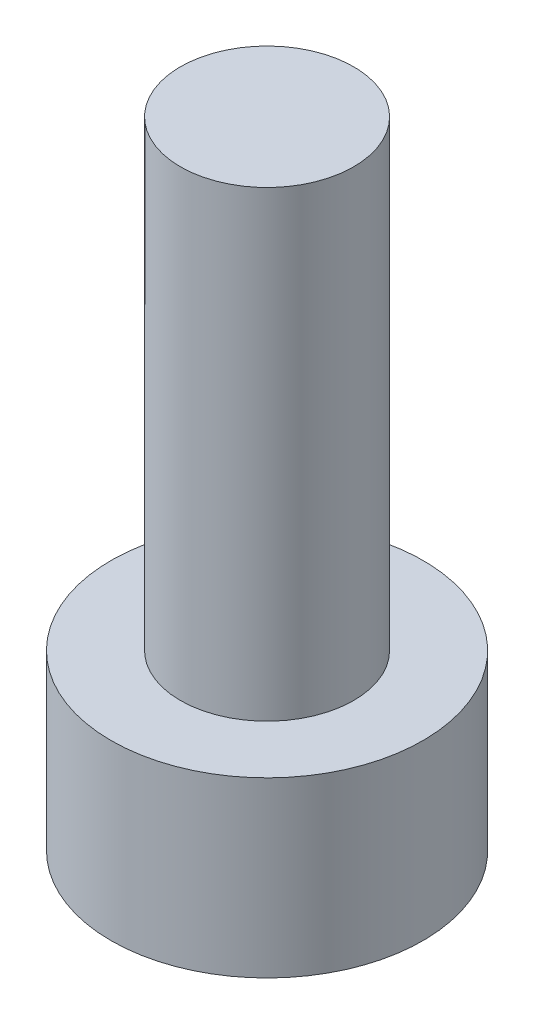
from build123d import *

# Parameters (mm, degrees)
SKETCH1_R           = 2.7
BOSS_EXTRUDE1_DEPTH = 3
SKETCH2_R           = 1.5
BOSS_EXTRUDE2_DEPTH = 8


with BuildPart() as part:
    # Sketch1 → Boss-Extrude1 (new body)
    with BuildSketch(Plane(origin=(0, 0, 0), x_dir=(1, 0, 0), z_dir=(0, 1, 0))):
        Circle(SKETCH1_R)
    extrude(amount=BOSS_EXTRUDE1_DEPTH)

    # Sketch2 → Boss-Extrude2 (add)
    with BuildSketch(Plane(origin=(0, 3, 0), x_dir=(1, 0, 0), z_dir=(0, 1, 0))):
        Circle(SKETCH2_R)
    extrude(amount=BOSS_EXTRUDE2_DEPTH)


solid = part.part
